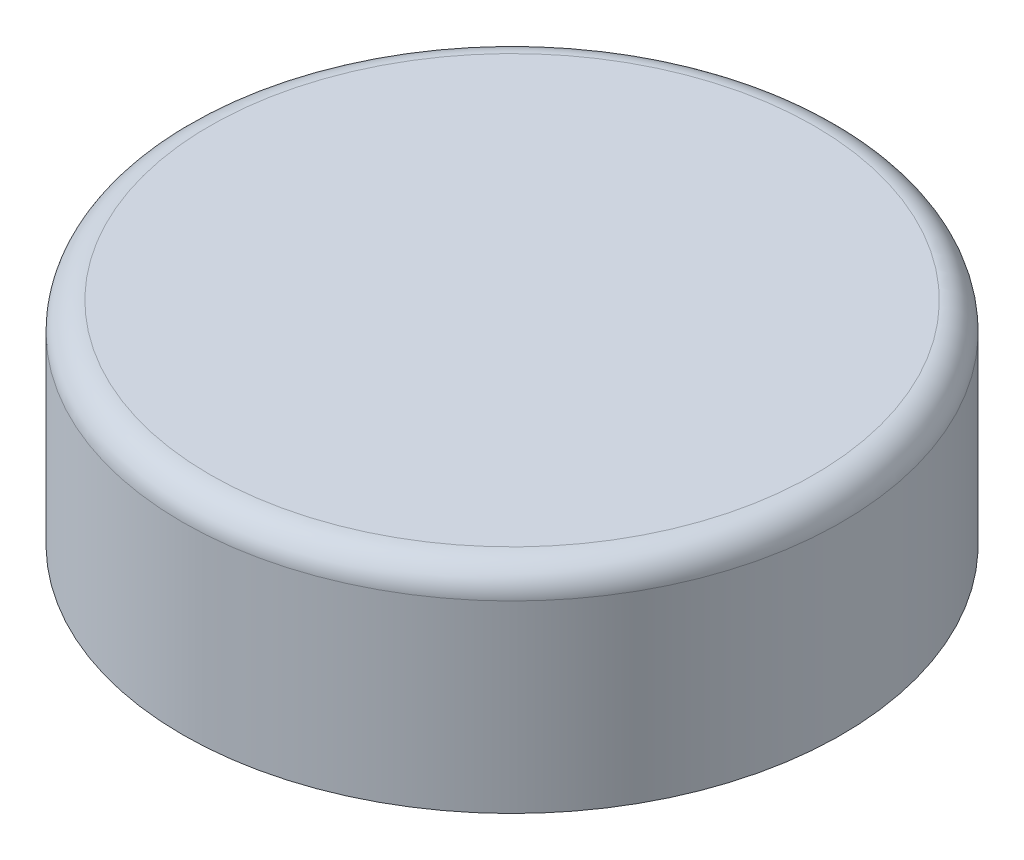
from build123d import *

# Parameters (mm, degrees)
SKETCH1_R           = 30.48
BOSS_EXTRUDE1_DEPTH = 19.558
FILLET1_R           = 2.54


with BuildPart() as part:
    # Sketch1 → Boss-Extrude1 (new body)
    with BuildSketch(Plane(origin=(0, 0, 0), x_dir=(1, 0, 0), z_dir=(0, 1, 0))):
        Circle(SKETCH1_R)
    extrude(amount=BOSS_EXTRUDE1_DEPTH)

    # Fillet1
    fillet1_edges = [part.edges().sort_by_distance(p)[0] for p in [
        (-30.48, 19.558, 0),
    ]]
    fillet(fillet1_edges, radius=FILLET1_R)


solid = part.part
